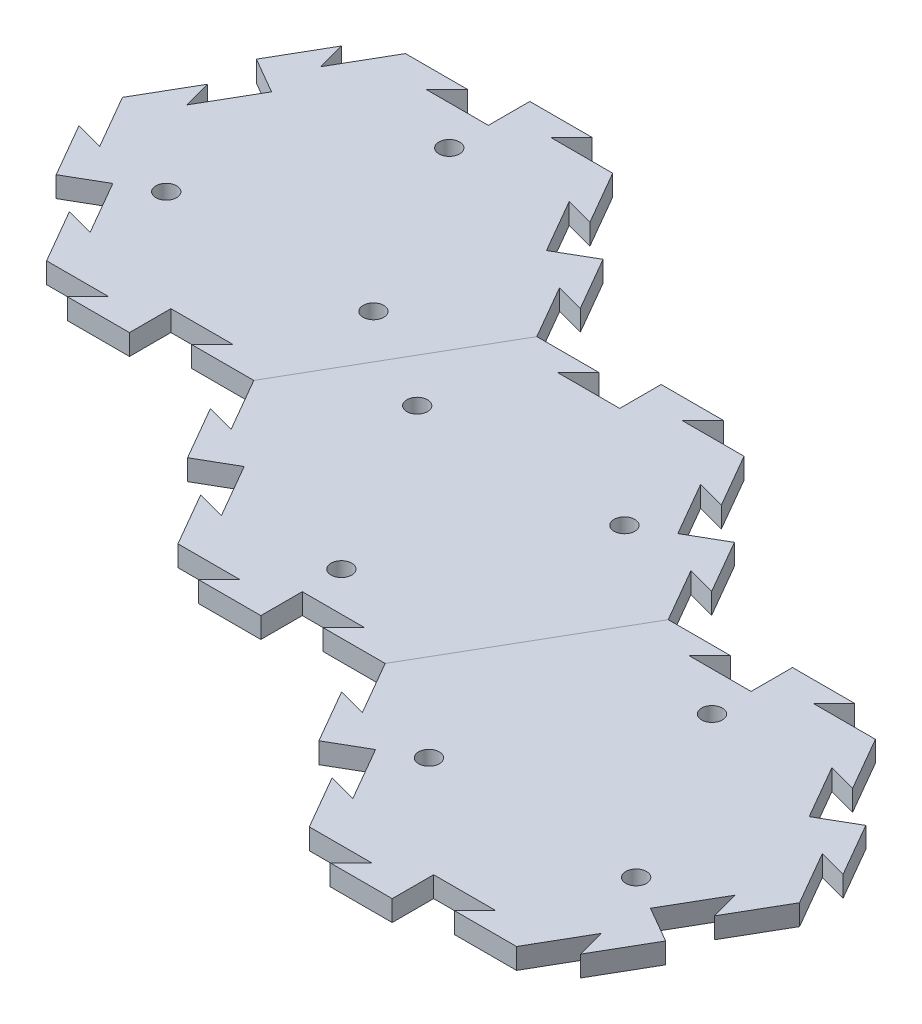
from build123d import *

# Parameters (mm, degrees)
BOSS_EXTRUDE1_DEPTH = 6.35
SKETCH9_R           = 3.175
CUT_EXTRUDE3_DEPTH  = 7.35
CIRPATTERN6_COUNT   = 3
CUT_EXTRUDE4_DEPTH  = 7.35
BOSS_EXTRUDE4_DEPTH = 6.35
CIRPATTERN7_COUNT   = 6
CUT_EXTRUDE5_DEPTH  = 7.35
BOSS_EXTRUDE5_DEPTH = 6.35
CIRPATTERN8_COUNT   = 6
CUT_EXTRUDE6_DEPTH  = 7.35
BOSS_EXTRUDE6_DEPTH = 6.35
CIRPATTERN9_COUNT   = 6


with BuildPart() as part:
    # Sketch1 → Boss-Extrude1 (new body)
    with BuildSketch(Plane(origin=(0, 0, 0), x_dir=(1, 0, 0), z_dir=(0, 1, 0))):
        Polygon((63.5, 0), (31.75, 54.99261314), (-31.75, 54.99261314), (-63.5, 0), (-31.75, -54.99261314), (31.75, -54.99261314), align=None)
    extrude(amount=-BOSS_EXTRUDE1_DEPTH)

    # Sketch9 → Cut-Extrude3 (cut, through all)
    with BuildSketch(Plane(origin=(0, 0, 0), x_dir=(1, 0, 0), z_dir=(0, 1, 0))):
        with Locations((-31.75, -18.330871047)):
            Circle(SKETCH9_R)
    cut_extrude3 = extrude(amount=-CUT_EXTRUDE3_DEPTH, mode=Mode.SUBTRACT)

    # CirPattern6: Cut-Extrude3 ×3 about axis
    cirpattern6_axis = Axis((0, 0, 0), (0, 1, 0))
    for i in range(1, CIRPATTERN6_COUNT):
        add(cut_extrude3.rotate(cirpattern6_axis, i * 360 / CIRPATTERN6_COUNT), mode=Mode.SUBTRACT)


with BuildPart() as body_2:
    # Mirror3: mirrored copy
    add(part.part.mirror(Plane(origin=(31.75, -6.35, 54.99261314), x_dir=(-0.5, 0, 0.866025404), z_dir=(0.866025404, 0, 0.5))))


with BuildPart() as part_1:
    add(part.part)

    # Sketch10 → Cut-Extrude4 (cut, through all)
    with BuildSketch(Plane(origin=(0, 0, 0), x_dir=(1, 0, 0), z_dir=(0, 1, 0))):
        Polygon((41.275, 38.494829198), (32.600738686, 40.819090512), (42.125738686, 24.32130657), (47.625, 27.49630657), align=None)
    cut_extrude4 = extrude(amount=-CUT_EXTRUDE4_DEPTH, mode=Mode.SUBTRACT)

    # Sketch11 → Boss-Extrude4 (add)
    with BuildSketch(Plane(origin=(0, 0, 0), x_dir=(1, 0, 0), z_dir=(0, 1, 0))):
        Polygon((47.625, 27.49630657), (53.124261314, 30.67130657), (62.649261314, 14.173522628), (53.975, 16.497783942), align=None)
    boss_extrude4 = extrude(amount=-BOSS_EXTRUDE4_DEPTH)

    # CirPattern7: Cut-Extrude4, Boss-Extrude4 ×6 about axis, 1 skipped
    cirpattern7_axis = Axis((0, 0, 0), (0, 1, 0))
    add([cut_extrude4.rotate(cirpattern7_axis, i * 360 / CIRPATTERN7_COUNT) for i in range(1, CIRPATTERN7_COUNT) if i not in (5,)], mode=Mode.SUBTRACT)
    add([boss_extrude4.rotate(cirpattern7_axis, i * 360 / CIRPATTERN7_COUNT) for i in range(1, CIRPATTERN7_COUNT) if i not in (5,)])


with BuildPart() as body_3:
    # Mirror4: mirrored copy
    add(body_2.part.mirror(Plane(origin=(158.75, -6.35, 54.99261314), x_dir=(-0.5, 0, 0.866025404), z_dir=(0.866025404, 0, 0.5))))

    # Sketch16 → Cut-Extrude6 (cut, through all)
    with BuildSketch(Plane(origin=(0, 0, 0), x_dir=(1, 0, 0), z_dir=(0, 1, 0))):
        Polygon((231.775, -71.490397082), (223.100738686, -69.166135768), (232.625738686, -85.66391971), (238.125, -82.48891971), align=None)
    cut_extrude6 = extrude(amount=-CUT_EXTRUDE6_DEPTH, mode=Mode.SUBTRACT)

    # Sketch17 → Boss-Extrude6 (add)
    with BuildSketch(Plane(origin=(0, 0, 0), x_dir=(1, 0, 0), z_dir=(0, 1, 0))):
        Polygon((238.125, -82.48891971), (243.624261314, -79.31391971), (253.149261314, -95.811703653), (244.475, -93.487442339), align=None)
    boss_extrude6 = extrude(amount=-BOSS_EXTRUDE6_DEPTH)

    # CirPattern9: Cut-Extrude6, Boss-Extrude6 ×6 about axis, 1 skipped
    cirpattern9_axis = Axis((190.5, 0, 109.985226281), (0, 1, 0))
    add([cut_extrude6.rotate(cirpattern9_axis, i * 360 / CIRPATTERN9_COUNT) for i in range(1, CIRPATTERN9_COUNT) if i not in (2,)], mode=Mode.SUBTRACT)
    add([boss_extrude6.rotate(cirpattern9_axis, i * 360 / CIRPATTERN9_COUNT) for i in range(1, CIRPATTERN9_COUNT) if i not in (2,)])


with BuildPart() as body_2_1:
    add(body_2.part)

    # Sketch13 → Cut-Extrude5 (cut, through all)
    with BuildSketch(Plane(origin=(0, 0, 0), x_dir=(1, 0, 0), z_dir=(0, 1, 0))):
        Polygon((136.525, -16.497783942), (127.850738686, -14.173522628), (137.375738686, -30.67130657), (142.875, -27.49630657), align=None)
    cut_extrude5 = extrude(amount=-CUT_EXTRUDE5_DEPTH, mode=Mode.SUBTRACT)

    # Sketch14 → Boss-Extrude5 (add)
    with BuildSketch(Plane(origin=(0, 0, 0), x_dir=(1, 0, 0), z_dir=(0, 1, 0))):
        Polygon((142.875, -27.49630657), (148.374261314, -24.32130657), (157.899261314, -40.819090512), (149.225, -38.494829198), align=None)
    boss_extrude5 = extrude(amount=-BOSS_EXTRUDE5_DEPTH)

    # CirPattern8: Cut-Extrude5, Boss-Extrude5 ×6 about axis, 2 skipped
    cirpattern8_axis = Axis((95.25, 0, 54.99261314), (0, 1, 0))
    add([cut_extrude5.rotate(cirpattern8_axis, i * 360 / CIRPATTERN8_COUNT) for i in range(1, CIRPATTERN8_COUNT) if i not in (2, 5)], mode=Mode.SUBTRACT)
    add([boss_extrude5.rotate(cirpattern8_axis, i * 360 / CIRPATTERN8_COUNT) for i in range(1, CIRPATTERN8_COUNT) if i not in (2, 5)])


solid = Compound([part_1.part, body_3.part, body_2_1.part])
